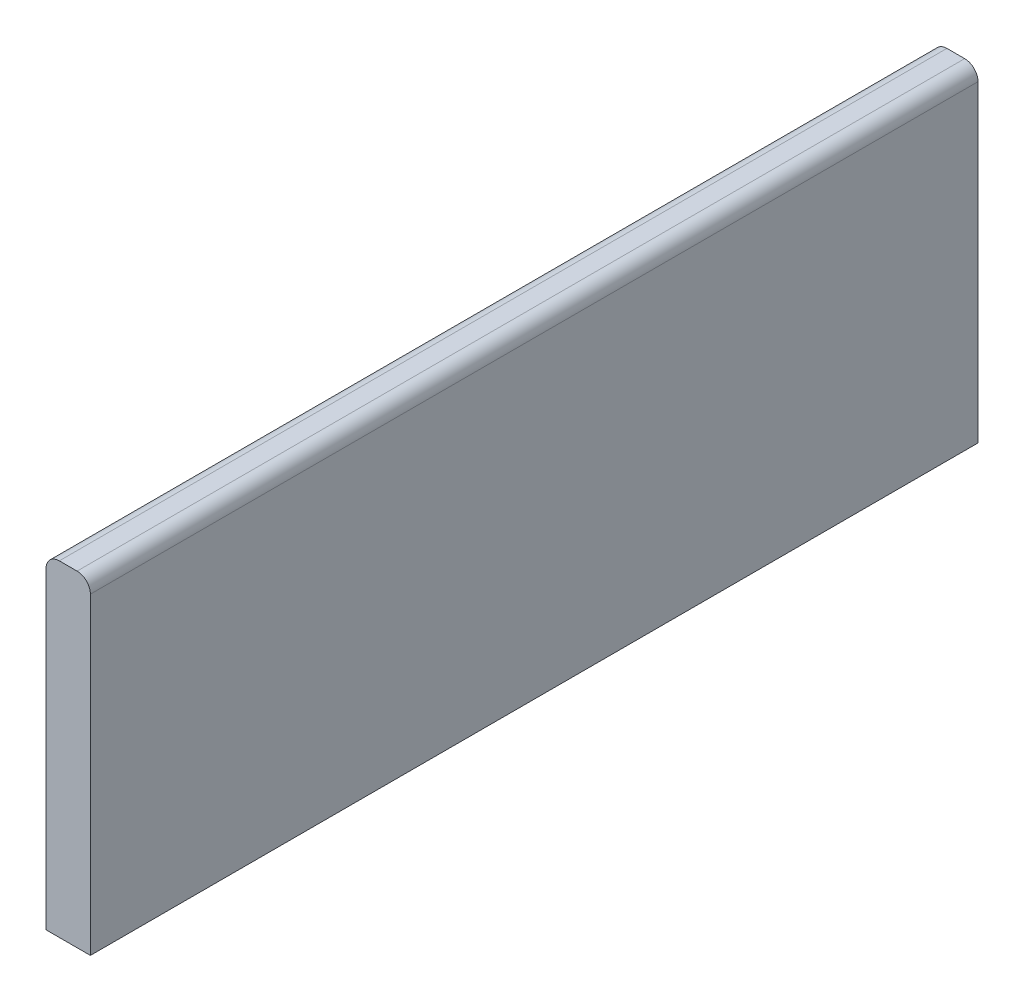
from build123d import *

# Parameters (mm, degrees)
ESQUISSE1_W        = 10
ESQUISSE1_H        = 73.5
BOSS_EXTRU_1_DEPTH = 200
CONG_1_R           = 3


with BuildPart() as part:
    # Esquisse1 → Boss.-Extru.1 (new body)
    with BuildSketch(Plane.XY):
        with Locations((109, -36.75)):
            Rectangle(ESQUISSE1_W, ESQUISSE1_H)
    extrude(amount=BOSS_EXTRU_1_DEPTH)

    # Congé1
    cong_1_edges = [part.edges().sort_by_distance(p)[0] for p in [
        (104, 0, 100),
        (114, 0, 100),
    ]]
    fillet(cong_1_edges, radius=CONG_1_R)


solid = part.part
